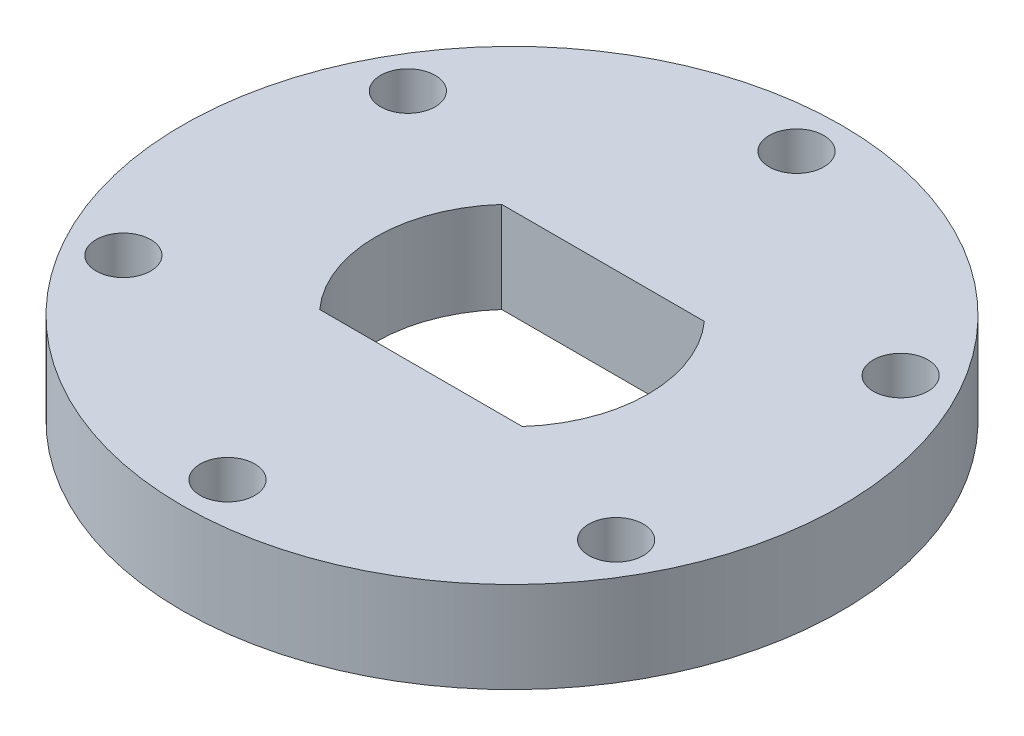
from build123d import *

# Parameters (mm, degrees)
SKETCH1_R           = 22.987
SKETCH1_R_2         = 1.905
BOSS_EXTRUDE1_DEPTH = 6.35


with BuildPart() as part:
    # Sketch1 → Boss-Extrude1 (new body)
    with BuildSketch(Plane(origin=(0, 0, 0), x_dir=(1, 0, 0), z_dir=(0, 1, 0))):
        Circle(SKETCH1_R)
        with Locations((0, 19.84375)):
            Circle(SKETCH1_R_2, mode=Mode.SUBTRACT)
        with Locations((17.185191606, 9.921875)):
            Circle(SKETCH1_R_2, mode=Mode.SUBTRACT)
        with Locations((17.185191606, -9.921875)):
            Circle(SKETCH1_R_2, mode=Mode.SUBTRACT)
        with Locations((0, -19.84375)):
            Circle(SKETCH1_R_2, mode=Mode.SUBTRACT)
        with Locations((-17.185191606, -9.921875)):
            Circle(SKETCH1_R_2, mode=Mode.SUBTRACT)
        with Locations((-17.185191606, 9.921875)):
            Circle(SKETCH1_R_2, mode=Mode.SUBTRACT)
        with BuildLine():
            Line((-7.065939428, -6.35), (7.065939428, -6.35))
            ThreePointArc((7.065939428, -6.35), (9.5, 0), (7.065939428, 6.35))
            Line((7.065939428, 6.35), (-7.065939428, 6.35))
            ThreePointArc((-7.065939428, 6.35), (-9.5, 0), (-7.065939428, -6.35))
        make_face(mode=Mode.SUBTRACT)
    extrude(amount=BOSS_EXTRUDE1_DEPTH)


solid = part.part
